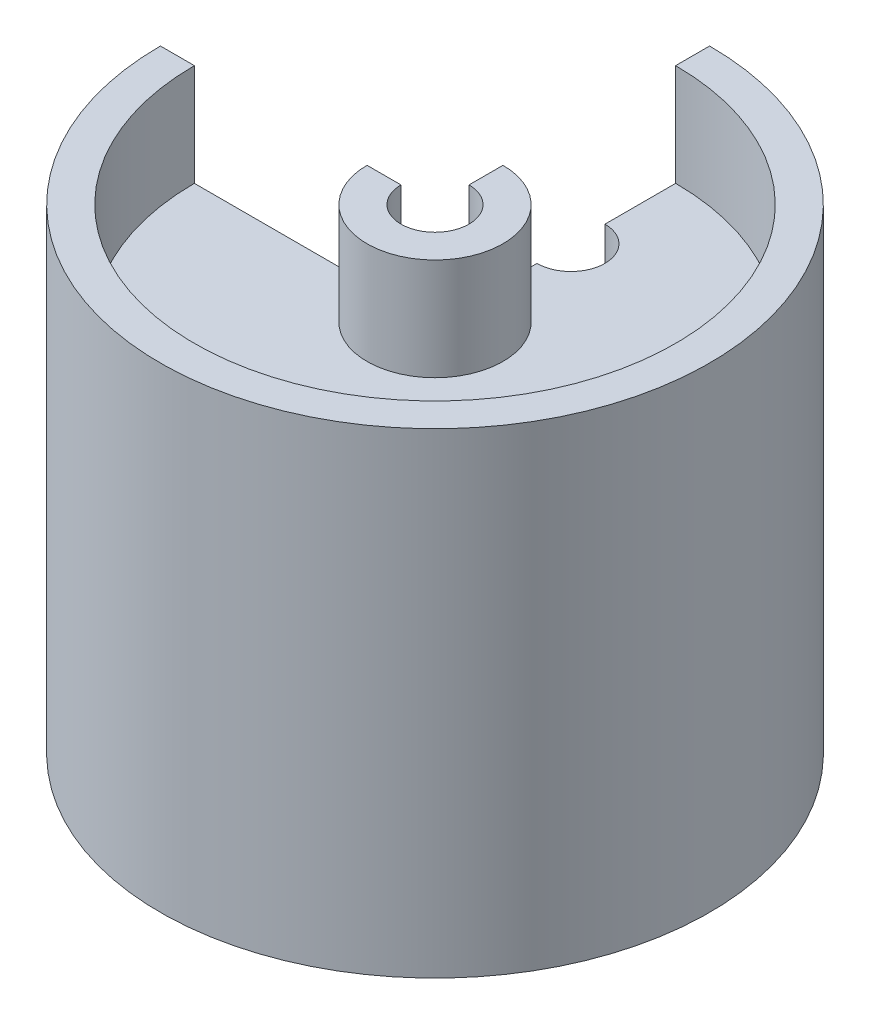
from build123d import *

# Parameters (mm, degrees)
REVOLVE2_ANGLE     = 270
SKETCH5_R          = 3.175
CUT_EXTRUDE1_DEPTH = 46.023434974


with BuildPart() as part:
    # Sketch1 → Revolve2 (revolve)
    with BuildSketch(Plane(origin=(0, 0, 0), x_dir=(0, 0, -1), z_dir=(1, 0, 0))):
        Polygon((22.479, 35.498434974), (22.479, 45.023434974), (25.654, 45.023434974), (25.654, 0.573434974), (22.479, 0.573434974), (22.479, 32.323434974), (6.35, 32.323434974), (6.35, 0.573434974), (3.175, 0.573434974), (3.175, 45.023434974), (6.35, 45.023434974), (6.35, 35.498434974), align=None)
    revolve(axis=Axis((0, 45.023434974, 0), (0, -1, 0)), revolution_arc=REVOLVE2_ANGLE)

    # Sketch5 → Cut-Extrude1 (cut, through all)
    with BuildSketch(Plane(origin=(0, 0, 0), x_dir=(1, 0, 0), z_dir=(0, 1, 0))):
        with Locations((0, 12.7)):
            Circle(SKETCH5_R)
    extrude(amount=CUT_EXTRUDE1_DEPTH, mode=Mode.SUBTRACT)


solid = part.part
